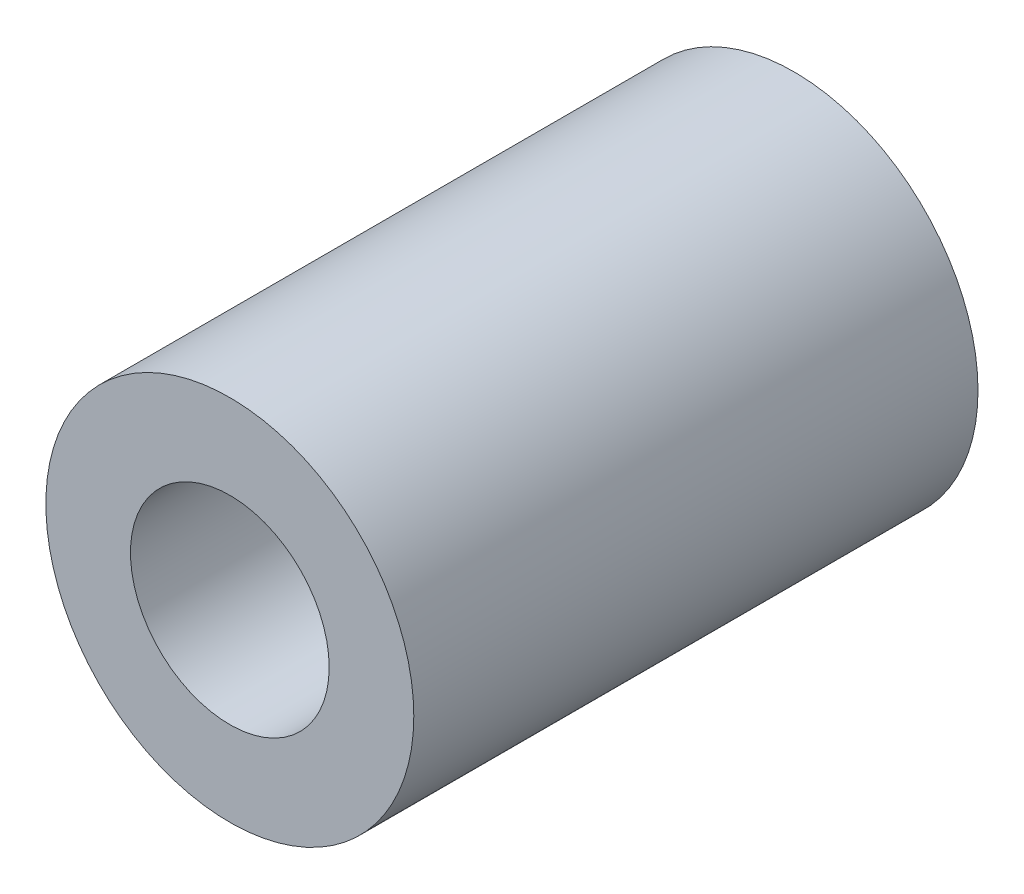
from build123d import *

# Parameters (mm, degrees)
SKETCH1_R           = 7.5
BOSS_EXTRUDE1_DEPTH = 23
SKETCH2_R           = 4.05
CUT_EXTRUDE1_DEPTH  = 24


with BuildPart() as part:
    # Sketch1 → Boss-Extrude1 (new body)
    with BuildSketch(Plane.XY):
        Circle(SKETCH1_R)
    extrude(amount=BOSS_EXTRUDE1_DEPTH)

    # Sketch2 → Cut-Extrude1 (cut, through all)
    with BuildSketch(Plane.XY.offset(23)):
        Circle(SKETCH2_R)
    extrude(amount=-CUT_EXTRUDE1_DEPTH, mode=Mode.SUBTRACT)


solid = part.part
